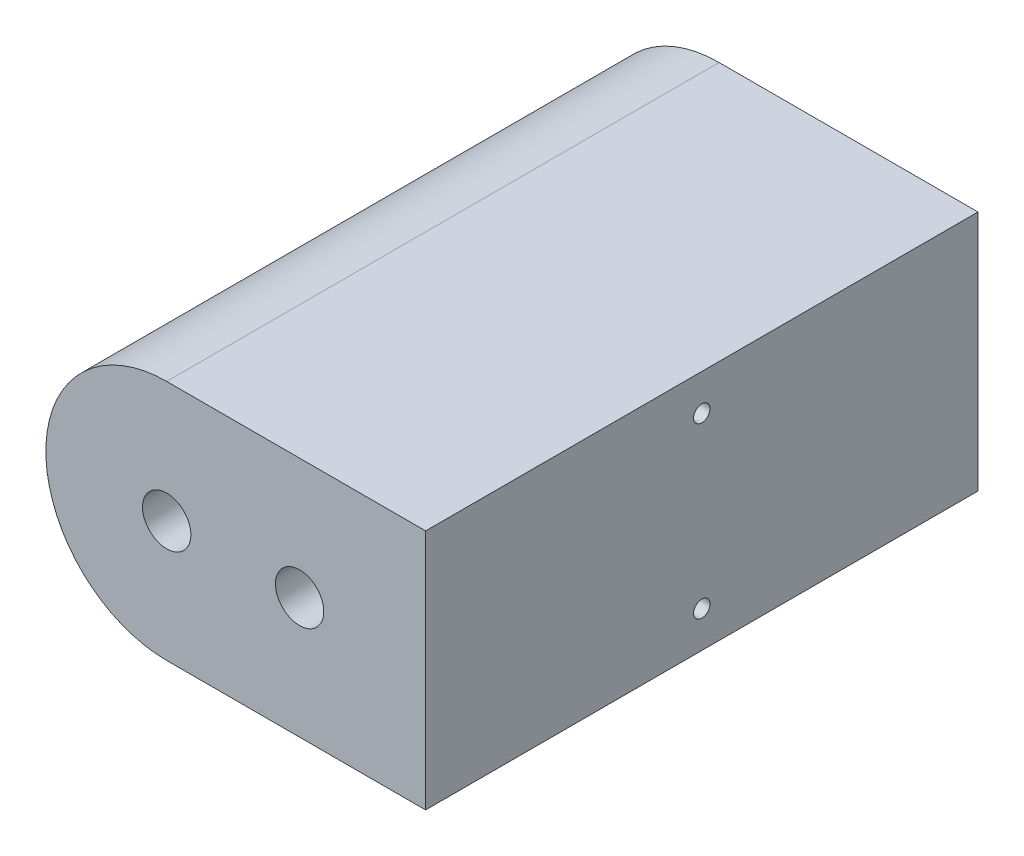
from build123d import *

# Parameters (mm, degrees)
BOSS_EXTRUDE1_DEPTH    = 160
SCALE1_SCALE           = 1.428571429
F_20_0MM_DOWEL_HOLE1_D = 20
M8_TAPPED_HOLE1_D      = 6.8
M8_TAPPED_HOLE1_DEPTH  = 22.25
M8_TAPPED_HOLE1_TIP    = 2.042926105


with BuildPart() as part:
    # Sketch1 → Boss-Extrude1 (new body)
    with BuildSketch(Plane.XY):
        with BuildLine():
            Line((0, 0), (-75, 0))
            ThreePointArc((-75, 0), (-110, 35), (-75, 70))
            Line((-75, 70), (0, 70))
            Line((0, 70), (0, 0))
        make_face()
    extrude(amount=BOSS_EXTRUDE1_DEPTH)


with BuildPart() as part_1:
    # Scale1: scaled about (-51.542183312, 35, 80)
    add(part.part.scale(SCALE1_SCALE).moved(Location((22.089507134, -15, -34.285714286))))

    # Ø20.0mm Dowel Hole1 (through all)
    with Locations(Plane(origin=(-30.053350009, 35, -34.285714286), x_dir=(-1, 0, 0), z_dir=(0, 0, -1))):
        with Locations((0, 0), (55, 0)):
            Hole(F_20_0MM_DOWEL_HOLE1_D / 2)

    # M8 Tapped Hole1
    with Locations(Plane(origin=(22.089507134, 0, 0), x_dir=(0, 0, -1), z_dir=(1, 0, 0))):
        with Locations((-80, 70), (-80, 0)):
            Hole(M8_TAPPED_HOLE1_D / 2, depth=M8_TAPPED_HOLE1_DEPTH)
            with Locations((0, 0, -(M8_TAPPED_HOLE1_DEPTH + M8_TAPPED_HOLE1_TIP / 2))):  # 118° drill point
                Cone(0, M8_TAPPED_HOLE1_D / 2, M8_TAPPED_HOLE1_TIP, mode=Mode.SUBTRACT)


solid = part_1.part
